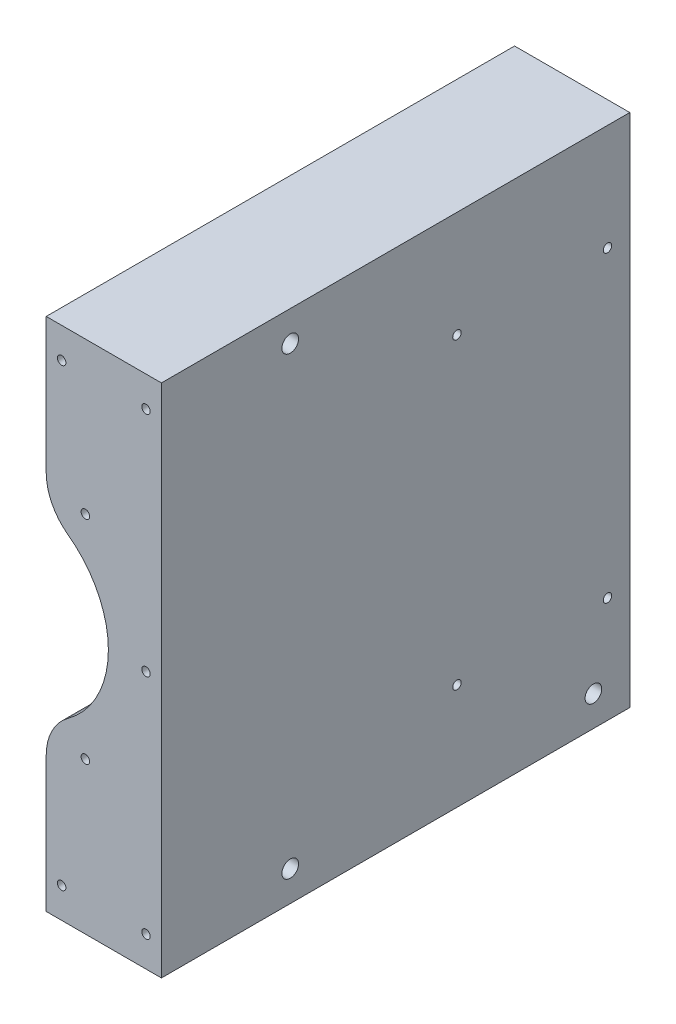
from build123d import *

# Parameters (mm, degrees)
SKETCH1_R           = 1.4
BOSS_EXTRUDE1_DEPTH = 154.5
SKETCH2_R           = 1.4
SKETCH2_R_2         = 2.75
CUT_EXTRUDE2_DEPTH  = 154.5


with BuildPart() as part:
    # Sketch1 → Boss-Extrude1 (new body)
    with BuildSketch(Plane.XY):
        with BuildLine():
            Line((-19, -40.36981468), (-19, -85))
            Line((-19, -85), (19, -85))
            Line((19, -85), (19, 85))
            Line((19, 85), (-19, 85))
            Line((-19, 85), (-19, 40.370425859))
            ThreePointArc((-19, 40.370425859), (-17.103490825, 32.446974965), (-11.825020107, 26.240883764))
            ThreePointArc((-11.825020107, 26.240883764), (1.499942552, 0.00030559), (-11.825020107, -26.240272585))
            ThreePointArc((-11.825020107, -26.240272585), (-17.103490825, -32.446363786), (-19, -40.36981468))
        make_face()
        with Locations((-6.083768895, -35)):
            Circle(SKETCH1_R, mode=Mode.SUBTRACT)
        with Locations((13.916231105, -75)):
            Circle(SKETCH1_R, mode=Mode.SUBTRACT)
        with Locations((-13.916231105, -75)):
            Circle(SKETCH1_R, mode=Mode.SUBTRACT)
        with Locations((13.916231105, 75)):
            Circle(SKETCH1_R, mode=Mode.SUBTRACT)
        with Locations((13.916231105, 0)):
            Circle(SKETCH1_R, mode=Mode.SUBTRACT)
        with Locations((-6.083768895, 35)):
            Circle(SKETCH1_R, mode=Mode.SUBTRACT)
        with Locations((-13.916231105, 75)):
            Circle(SKETCH1_R, mode=Mode.SUBTRACT)
    extrude(amount=BOSS_EXTRUDE1_DEPTH)

    # Sketch2 → Cut-Extrude2 (cut)
    with BuildSketch(Plane(origin=(19, 0, 0), x_dir=(0, 0, -1), z_dir=(1, 0, 0))):
        with Locations((-7.348742235, 50.000002621)):
            Circle(SKETCH2_R)
        with Locations((-56.999663733, 50.000002621)):
            Circle(SKETCH2_R)
        with Locations((-7.348742235, -49.999997379)):
            Circle(SKETCH2_R)
        with Locations((-56.999663733, -49.999997379)):
            Circle(SKETCH2_R)
        with Locations((-11.999663733, -74.999997379)):
            Circle(SKETCH2_R_2)
        with Locations((-111.999663733, -74.999997379)):
            Circle(SKETCH2_R_2)
        with Locations((-111.999663733, 75.000002621)):
            Circle(SKETCH2_R_2)
    extrude(amount=-CUT_EXTRUDE2_DEPTH, mode=Mode.SUBTRACT)


solid = part.part
